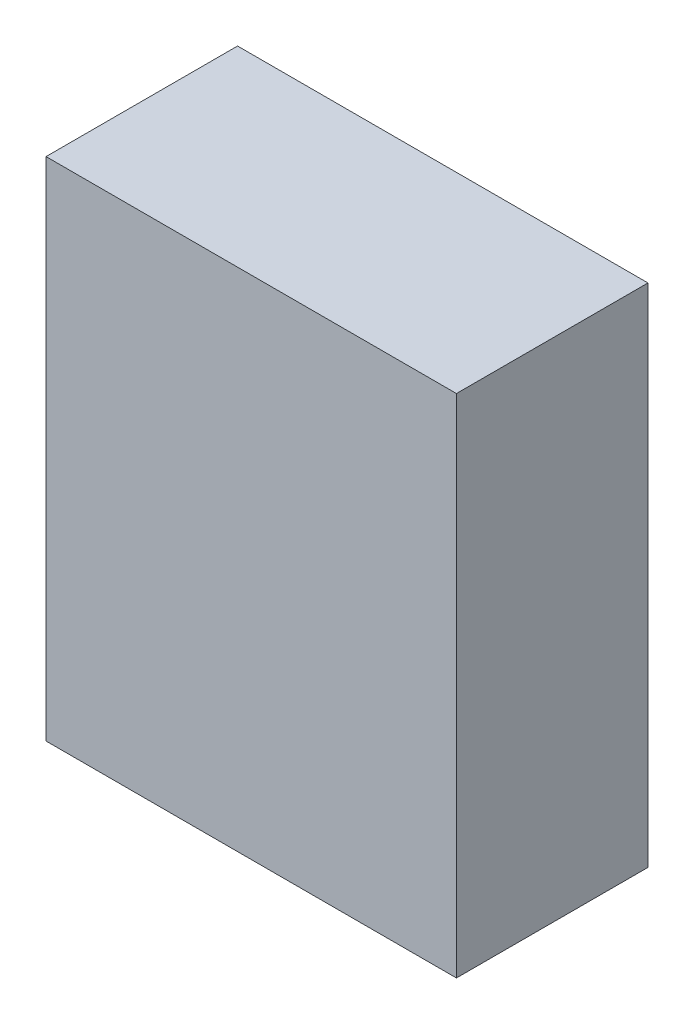
from build123d import *

# Parameters (mm, degrees)
SKETCH1_W           = 47.625
SKETCH1_H           = 58.7375
BOSS_EXTRUDE1_DEPTH = 22.225


with BuildPart() as part:
    # Sketch1 → Boss-Extrude1 (new body)
    with BuildSketch(Plane.XY):
        Rectangle(SKETCH1_W, SKETCH1_H)
    extrude(amount=BOSS_EXTRUDE1_DEPTH)


solid = part.part
